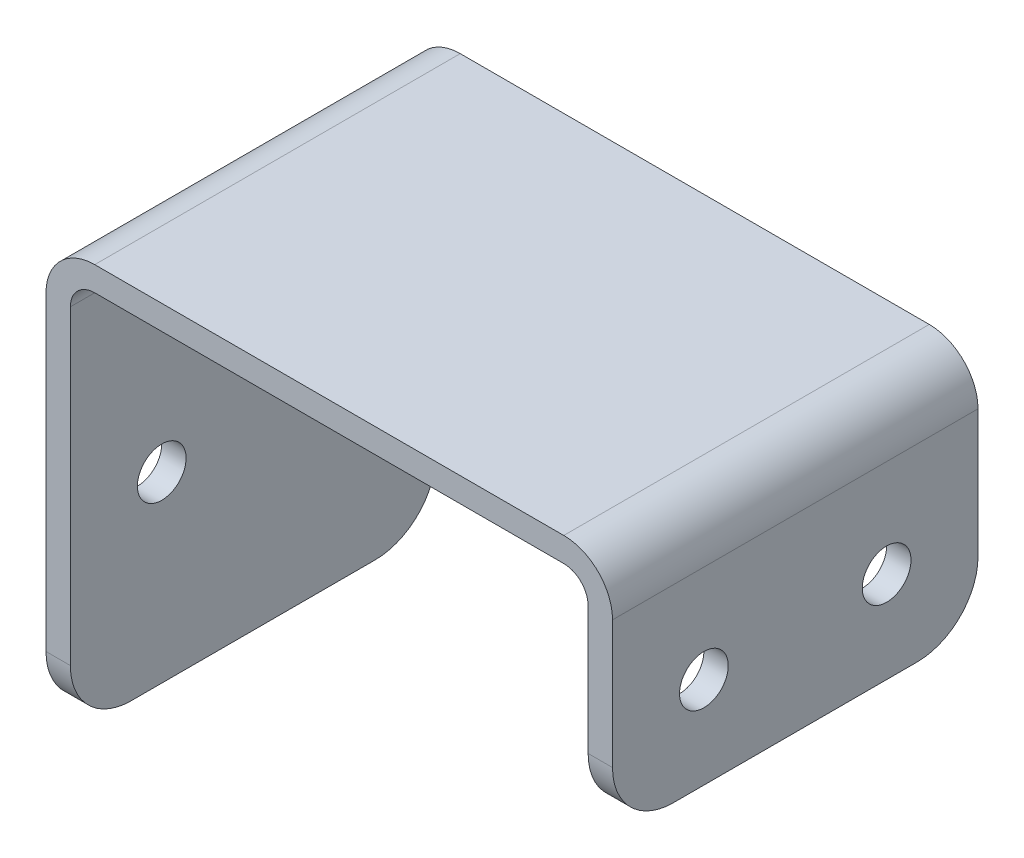
from build123d import *

# Parameters (mm, degrees)
EXTRUDE_1_DEPTH     = 60
CUT_EXTRUDE_1_REACH = 95
SKETCH_2_R          = 4
FILLET_1_R          = 10
CUT_EXTRUDE_2_REACH = 95
SKETCH_3_R          = 4


with BuildPart() as part:
    # 草图1 → 凸台-拉伸1 (new body)
    with BuildSketch(Plane.XY):
        with BuildLine():
            Line((-42.5, 0), (-42.5, 61))
            ThreePointArc((-42.5, 61), (-41.328427125, 63.828427125), (-38.5, 65))
            Line((-38.5, 65), (38.5, 65))
            ThreePointArc((38.5, 65), (41.328427125, 63.828427125), (42.5, 61))
            Line((42.5, 61), (42.5, 30))
            Line((42.5, 30), (46.5, 30))
            Line((46.5, 30), (46.5, 61))
            ThreePointArc((46.5, 61), (44.156854249, 66.656854249), (38.5, 69))
            Line((38.5, 69), (-38.5, 69))
            ThreePointArc((-38.5, 69), (-44.156854249, 66.656854249), (-46.5, 61))
            Line((-46.5, 61), (-46.5, 0))
            Line((-46.5, 0), (-42.5, 0))
        make_face()
    extrude(amount=EXTRUDE_1_DEPTH)

    # 草图2 → 切除-拉伸1 (cut, up to next)
    with BuildSketch(Plane.ZY.offset(46.5), mode=Mode.PRIVATE) as cut_extrude_1_sk1:
        with Locations((15, 30)):
            Circle(SKETCH_2_R)
    cut_extrude_1_tool1 = extrude(cut_extrude_1_sk1.sketch, amount=-CUT_EXTRUDE_1_REACH, mode=Mode.PRIVATE) & part.part
    add(cut_extrude_1_tool1.solids().sort_by_distance((-46.5, 30, 15))[0], mode=Mode.SUBTRACT)
    # 草图2 → 切除-拉伸1 (cut, up to next)
    with BuildSketch(Plane.ZY.offset(46.5), mode=Mode.PRIVATE) as cut_extrude_1_sk2:
        with Locations((45, 30)):
            Circle(SKETCH_2_R)
    cut_extrude_1_tool2 = extrude(cut_extrude_1_sk2.sketch, amount=-CUT_EXTRUDE_1_REACH, mode=Mode.PRIVATE) & part.part
    add(cut_extrude_1_tool2.solids().sort_by_distance((-46.5, 30, 45))[0], mode=Mode.SUBTRACT)

    # 圆角1
    fillet_1_edges = [part.edges().sort_by_distance(p)[0] for p in [
        (44.5, 30, 0),
        (-44.5, 0, 0),
        (44.5, 30, 60),
        (-44.5, 0, 60),
    ]]
    fillet(fillet_1_edges, radius=FILLET_1_R)

    # 草图3 → 切除-拉伸2 (cut, up to next)
    with BuildSketch(Plane(origin=(46.5, 0, 0), x_dir=(0, 0, -1), z_dir=(1, 0, 0)), mode=Mode.PRIVATE) as cut_extrude_2_sk1:
        with Locations((-45, 45)):
            Circle(SKETCH_3_R)
    cut_extrude_2_tool1 = extrude(cut_extrude_2_sk1.sketch, amount=-CUT_EXTRUDE_2_REACH, mode=Mode.PRIVATE) & part.part
    add(cut_extrude_2_tool1.solids().sort_by_distance((46.5, 45, 45))[0], mode=Mode.SUBTRACT)
    # 草图3 → 切除-拉伸2 (cut, up to next)
    with BuildSketch(Plane(origin=(46.5, 0, 0), x_dir=(0, 0, -1), z_dir=(1, 0, 0)), mode=Mode.PRIVATE) as cut_extrude_2_sk2:
        with Locations((-15, 45)):
            Circle(SKETCH_3_R)
    cut_extrude_2_tool2 = extrude(cut_extrude_2_sk2.sketch, amount=-CUT_EXTRUDE_2_REACH, mode=Mode.PRIVATE) & part.part
    add(cut_extrude_2_tool2.solids().sort_by_distance((46.5, 45, 15))[0], mode=Mode.SUBTRACT)


solid = part.part
